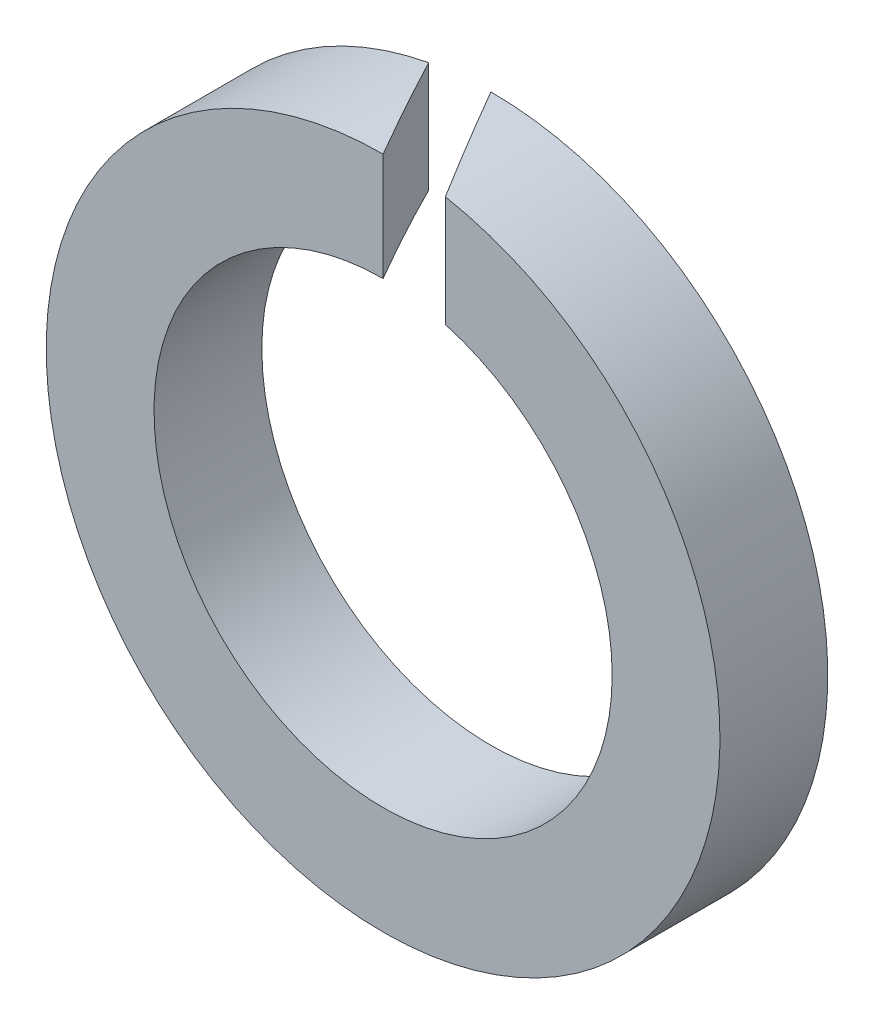
from build123d import *

# Parameters (mm, degrees)
SKETCH1_R          = 2.5
SKETCH1_R_2        = 1.7
BASE_EXTRUDE_DEPTH = 0.8
CUT_EXTRUDE1_DEPTH = 3.5


with BuildPart() as part:
    # Sketch1 → Base-Extrude (new body)
    with BuildSketch(Plane.XY):
        Circle(SKETCH1_R)
        Circle(SKETCH1_R_2, mode=Mode.SUBTRACT)
    extrude(amount=-BASE_EXTRUDE_DEPTH)

    # Sketch2 → Cut-Extrude1 (cut, through all)
    with BuildSketch(Plane(origin=(0, 0, 0), x_dir=(1, 0, 0), z_dir=(0, 1, 0))):
        Polygon((0, 0.8), (0.461880215, 0), (0, 0), (-0.461880215, 0.8), align=None)
    extrude(amount=CUT_EXTRUDE1_DEPTH, mode=Mode.SUBTRACT)


solid = part.part
